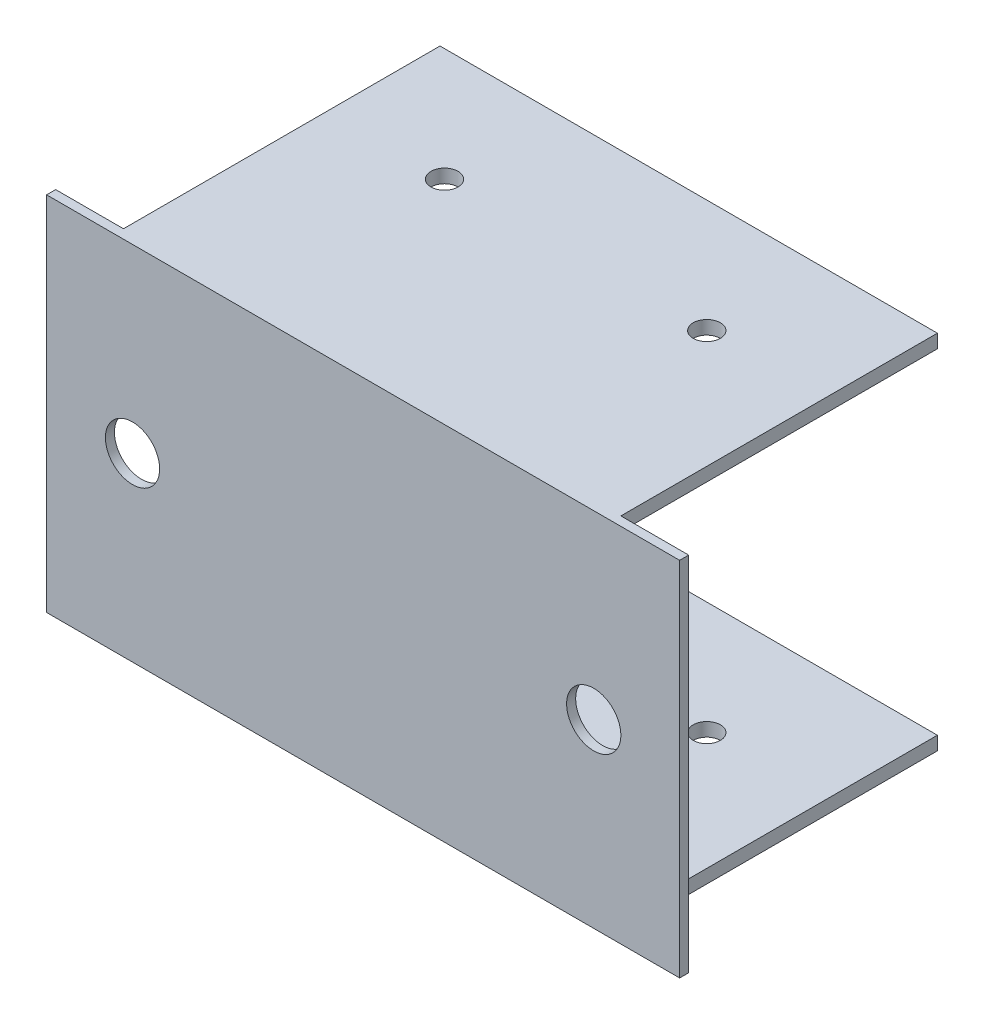
from build123d import *

# Parameters (mm, degrees)
SKETCH_1_W          = 70
SKETCH_1_H          = 40
EXTRUDE_1_DEPTH     = 1
SKETCH_2_R          = 3
CUT_EXTRUDE_1_DEPTH = 10
SKETCH_4_W          = 55
SKETCH_4_H          = 36
EXTRUDE_2_DEPTH     = 1.5
EXTRUDE_START       = -40
SKETCH_4_2_W        = 55
SKETCH_4_2_H        = 36
EXTRUDE_3_DEPTH     = 1.5
SKETCH_5_R          = 1.5
CUT_EXTRUDE_2_DEPTH = 64.639610307


with BuildPart() as part:
    # 草图1 → 凸台-拉伸1 (new body)
    with BuildSketch(Plane.XY):
        Rectangle(SKETCH_1_W, SKETCH_1_H)
    extrude(amount=EXTRUDE_1_DEPTH)

    # 草图2 → 切除-拉伸1 (cut)
    with BuildSketch(Plane.XY.offset(1)):
        with Locations((-25.5, 0)):
            Circle(SKETCH_2_R)
        with Locations((25.5, 0)):
            Circle(SKETCH_2_R)
    extrude(amount=-CUT_EXTRUDE_1_DEPTH, mode=Mode.SUBTRACT)

    # 草图4 → 凸台-拉伸2 (add)
    with BuildSketch(Plane(origin=(0, 20, 0), x_dir=(1, 0, 0), z_dir=(0, 1, 0))):
        with Locations((0, 17)):
            Rectangle(SKETCH_4_W, SKETCH_4_H)
    extrude(amount=-EXTRUDE_2_DEPTH)

    # 草图4<2> → 凸台-拉伸3 (add)
    with BuildSketch(Plane(origin=(0, 20, 0), x_dir=(1, 0, 0), z_dir=(0, 1, 0)).offset(EXTRUDE_START)):
        with Locations((0, 17)):
            Rectangle(SKETCH_4_2_W, SKETCH_4_2_H)
    extrude(amount=EXTRUDE_3_DEPTH)

    # 草图5 → 切除-拉伸2 (cut, through all)
    with BuildSketch(Plane(origin=(0, 20, 0), x_dir=(1, 0, 0), z_dir=(0, 1, 0))):
        with Locations((-14.5, 22.5)):
            Circle(SKETCH_5_R)
        with Locations((14.5, 22.5)):
            Circle(SKETCH_5_R)
    extrude(amount=-CUT_EXTRUDE_2_DEPTH, mode=Mode.SUBTRACT)


solid = part.part
